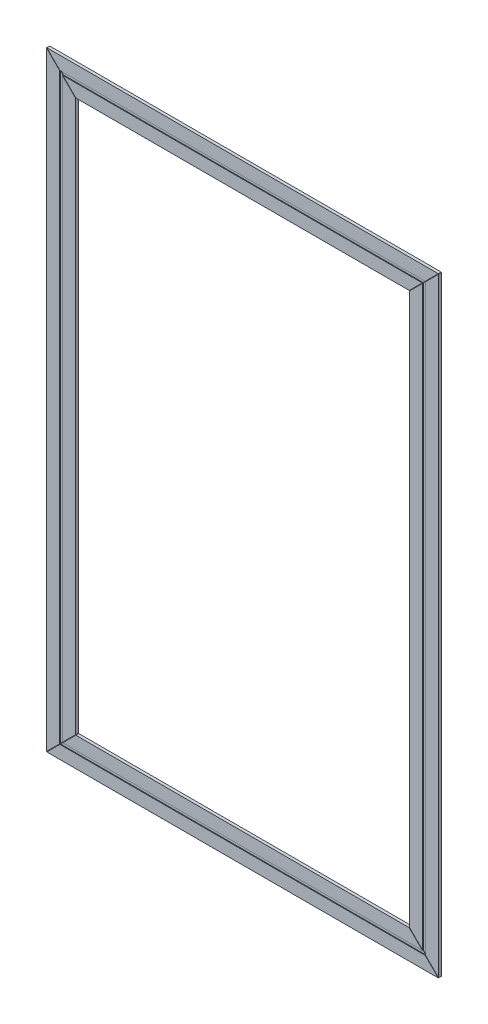
from build123d import *

# Parameters (mm, degrees)
CROQUIS1_W                = 248
CROQUIS1_H                = 398
CROQUIS1_W_2              = 230
CROQUIS1_H_2              = 380
SALIENTE_EXTRUIR1_DEPTH   = 2
CROQUIS1_W_3              = 270
CROQUIS1_H_3              = 420
CROQUIS1_W_4              = 252
CROQUIS1_H_4              = 402
SALIENTE_EXTRUIR1_2_DEPTH = 2
CROQUIS1_3_W              = 252
CROQUIS1_3_H              = 402
CROQUIS1_3_W_2            = 248
CROQUIS1_3_H_2            = 398
SALIENTE_EXTRUIR2_DEPTH   = 1.5
CORTAR_EXTRUIR1_DEPTH     = 21


with BuildPart() as part:
    # Croquis1 → Saliente-Extruir1 (new body)
    with BuildSketch(Plane.XY):
        Rectangle(CROQUIS1_W, CROQUIS1_H)
        Rectangle(CROQUIS1_W_2, CROQUIS1_H_2, mode=Mode.SUBTRACT)
    extrude(amount=SALIENTE_EXTRUIR1_DEPTH)



with BuildPart() as body_2:
    # Croquis1 → Saliente-Extruir1 2 (new body)
    with BuildSketch(Plane.XY):
        Rectangle(CROQUIS1_W_3, CROQUIS1_H_3)
        Rectangle(CROQUIS1_W_4, CROQUIS1_H_4, mode=Mode.SUBTRACT)
    extrude(amount=SALIENTE_EXTRUIR1_2_DEPTH)


with BuildPart() as part_1:
    add(part.part)

    add(body_2.part)  # Saliente-Extruir2 merges body 2
    # Croquis1_3 → Saliente-Extruir2 (add)
    with BuildSketch(Plane.XY):
        Rectangle(CROQUIS1_3_W, CROQUIS1_3_H)
        Rectangle(CROQUIS1_3_W_2, CROQUIS1_3_H_2, mode=Mode.SUBTRACT)
    extrude(amount=SALIENTE_EXTRUIR2_DEPTH)

    # Croquis2 → Cortar-Extruir1 (cut)
    with BuildSketch(Plane.XY.offset(2)):
        Polygon((-115, 189.8), (-135, 209.8), (-135, 210), (-134.8, 210), (-114.8, 190), (-115, 190), align=None)
        Polygon((115, 190), (115, 189.8), (135, 209.8), (135, 210), (134.8, 210), (114.8, 190), align=None)
        Polygon((115, -189.8), (135, -209.8), (135, -210), (134.8, -210), (114.8, -190), (115, -190), align=None)
        Polygon((-115, -190), (-115, -189.8), (-135, -209.8), (-135, -210), (-134.8, -210), (-114.8, -190), align=None)
    extrude(amount=-CORTAR_EXTRUIR1_DEPTH, mode=Mode.SUBTRACT)


with BuildPart() as cortar_extruir1_piece_1:
    # of the separate pieces the step leaves, piece 1, a body of its own (cortar_extruir1_pieces)
    add(part_1.part.solids().sort_by_distance((124, 198.8, 1.5))[0])


with BuildPart() as cortar_extruir1_piece_2:
    # of the separate pieces the step leaves, piece 2, a body of its own (cortar_extruir1_pieces)
    add(part_1.part.solids().sort_by_distance((-124, 198.8, 2))[0])


with BuildPart() as cortar_extruir1_piece_3:
    # of the separate pieces the step leaves, piece 3, a body of its own (cortar_extruir1_pieces)
    add(part_1.part.solids().sort_by_distance((123.8, 199, 2))[0])


with BuildPart() as cortar_extruir1_piece_4:
    # of the separate pieces the step leaves, piece 4, a body of its own (cortar_extruir1_pieces)
    add(part_1.part.solids().sort_by_distance((123.8, -199, 2))[0])


solid = Compound([cortar_extruir1_piece_1.part, cortar_extruir1_piece_2.part, cortar_extruir1_piece_3.part, cortar_extruir1_piece_4.part])
